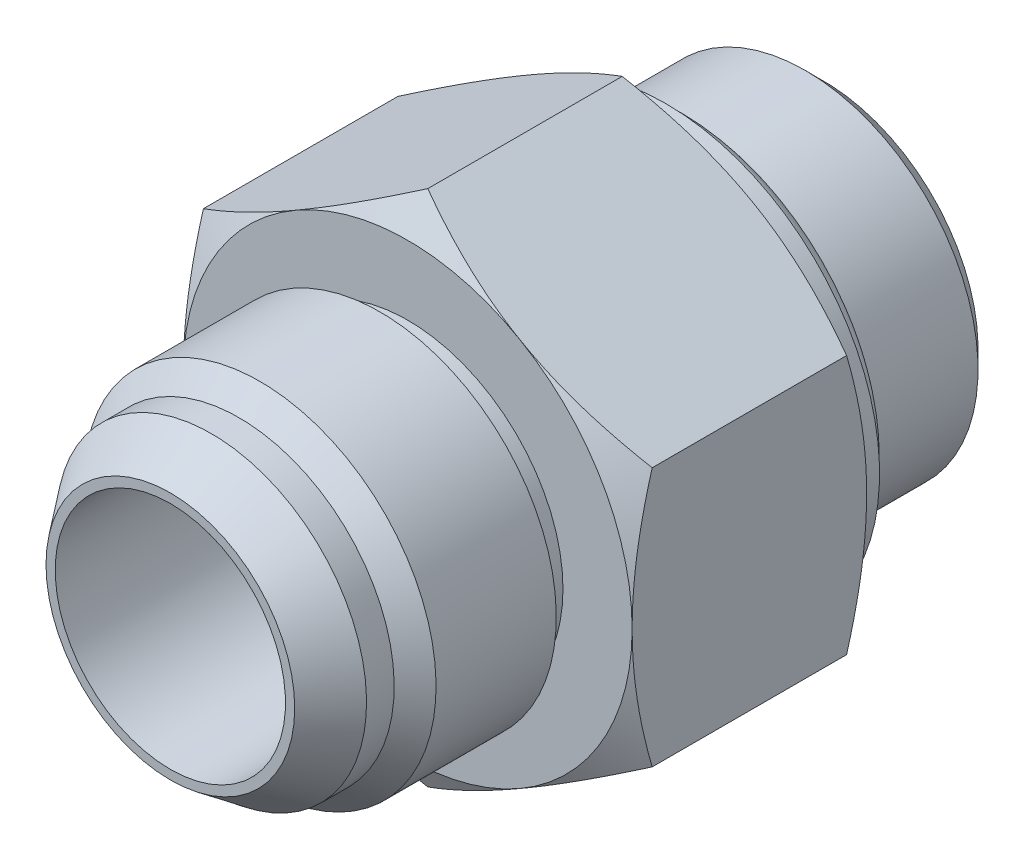
from build123d import *

# Parameters (mm, degrees)
BOSS_EXTRUDE1_START = -11.142345
BOSS_EXTRUDE1_DEPTH = 17.961379
SKETCH3_OUTSIDE_W   = 113.156
SKETCH3_OUTSIDE_H   = 118.474
SKETCH3_OUTSIDE_R   = 17.18691
CUT_EXTRUDE1_DEPTH  = 18.961379091
CUT_EXTRUDE1_TAPER  = 60
SKETCH4_OUTSIDE_W   = 113.156
SKETCH4_OUTSIDE_H   = 118.474
SKETCH4_OUTSIDE_R   = 17.18691
CUT_EXTRUDE2_DEPTH  = 18.961379091
CUT_EXTRUDE2_TAPER  = 60


with BuildPart() as part:
    # Sketch2 → Boss-Extrude1 (new body)
    with BuildSketch(Plane.XY.offset(BOSS_EXTRUDE1_START)):
        Polygon((0, 19.84573423), (-17.18691, 9.922867115), (-17.18691, -9.922867115), (0, -19.84573423), (17.18691, -9.922867115), (17.18691, 9.922867115), align=None)
    extrude(amount=BOSS_EXTRUDE1_DEPTH)

    # Sketch3 outside → Cut-Extrude1 (cut, through all)
    with BuildSketch(Plane.XY.offset(6.819034091)):
        Rectangle(SKETCH3_OUTSIDE_W, SKETCH3_OUTSIDE_H)
        Circle(SKETCH3_OUTSIDE_R, mode=Mode.SUBTRACT)
    extrude(amount=-CUT_EXTRUDE1_DEPTH, taper=CUT_EXTRUDE1_TAPER, mode=Mode.SUBTRACT)

    # Sketch4 outside → Cut-Extrude2 (cut, through all)
    with BuildSketch(Plane(origin=(0, 0, -11.142345), x_dir=(-1, 0, 0), z_dir=(0, 0, -1))):
        Rectangle(SKETCH4_OUTSIDE_W, SKETCH4_OUTSIDE_H)
        Circle(SKETCH4_OUTSIDE_R, mode=Mode.SUBTRACT)
    extrude(amount=-CUT_EXTRUDE2_DEPTH, taper=CUT_EXTRUDE2_TAPER, mode=Mode.SUBTRACT)

    # Sketch5 → Revolve1 (revolve)
    with BuildSketch(Plane(origin=(0, 0, 0), x_dir=(0, 0, -1), z_dir=(1, 0, 0))):
        Polygon((-25.003125, 0), (-25.003125, 9.525), (-21.86493102, 11.889798783), (-19.748264354, 11.889798783), (-18.144313137, 13.49375), (-8.935700758, 13.49375), (-8.009659091, 11.889798783), (2.161655455, 11.889798783), (2.161655455, 13.2207), (11.142345, 13.2207), (11.142345, 11.695920437), (13.410202143, 11.695920437), (13.965176518, 13.2207), (23.642410714, 13.2207), (25.003125, 11.859985714), (25.003125, 0), align=None)
    revolve(axis=Axis((0, 0, 25.003125), (0, 0, -1)))

    # Sketch6 → Cut-Revolve1 (revolve, cut)
    with BuildSketch(Plane(origin=(0, 0, 0), x_dir=(0, 0, -1), z_dir=(1, 0, 0))):
        Polygon((-25.003125, 8.819444444), (11.142345, 8.819444444), (11.142345, 9.51877758), (25.003125, 9.51877758), (25.003125, 0), (-25.003125, 0), align=None)
    revolve(axis=Axis((0, 0, -25.003125), (0, 0, 1)), mode=Mode.SUBTRACT)


with BuildPart() as body_2:
    # Sketch11 → Revolve2 (revolve)
    with BuildSketch(Plane(origin=(0, 0, 0), x_dir=(0, 0, -1), z_dir=(1, 0, 0))):
        with BuildLine():
            Line((11.142345, 11.695920437), (11.142345, 16.363261566))
            Line((11.142345, 16.363261566), (12.956630714, 16.363261566))
            Line((12.956630714, 16.363261566), (12.956630714, 15.662448144))
            ThreePointArc((12.956630714, 15.662448144), (14.589487857, 14.029591001), (12.956630714, 12.396733858))
            Line((12.956630714, 12.396733858), (12.956630714, 11.695920437))
            Line((12.956630714, 11.695920437), (11.142345, 11.695920437))
        make_face()
    revolve(axis=Axis((0, 0, 25.003125), (0, 0, -1)))


solid = Compound([part.part, body_2.part])
